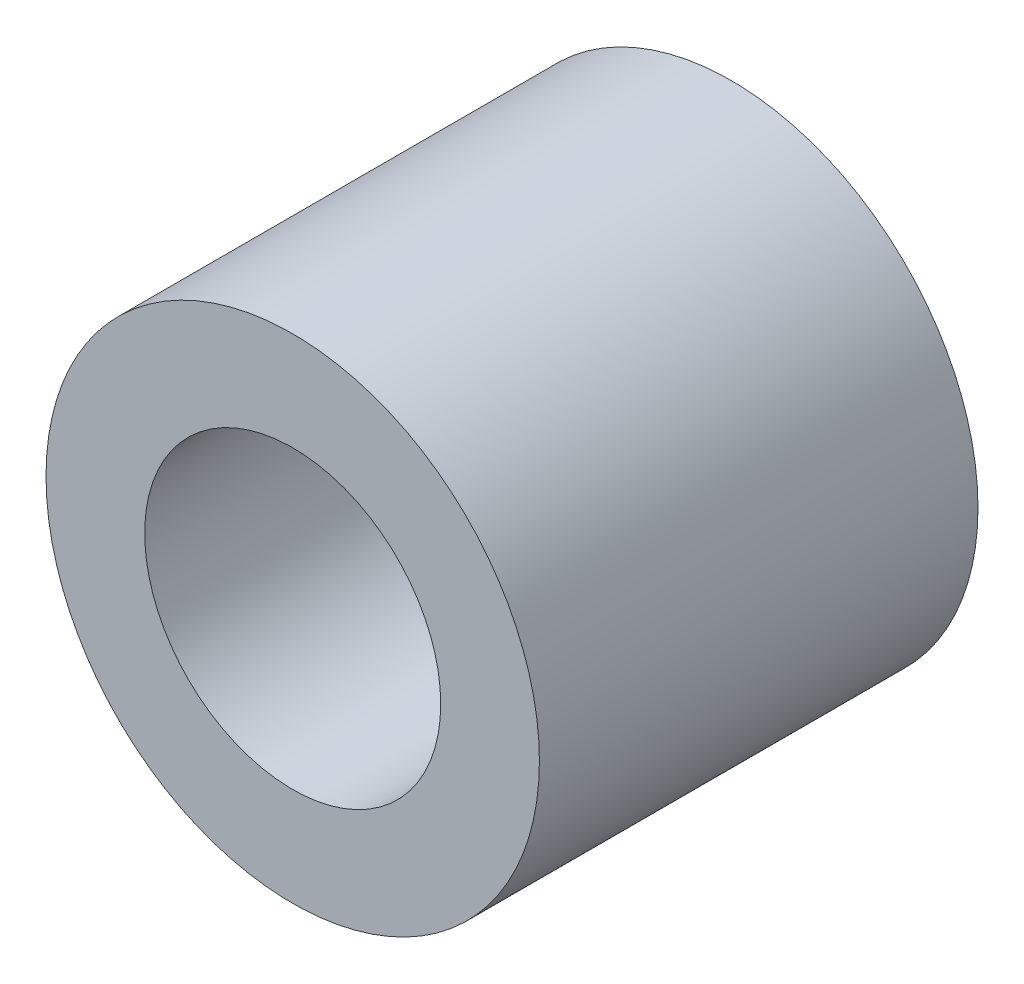
from build123d import *

# Parameters (mm, degrees)
SKETCH1_R      = 2.25
SKETCH1_R_2    = 1.35
EXTRUDE1_DEPTH = 2


with BuildPart() as part:
    # Sketch1 → Extrude1 (new body, symmetric)
    with BuildSketch(Plane.XY):
        Circle(SKETCH1_R)
        Circle(SKETCH1_R_2, mode=Mode.SUBTRACT)
    extrude(amount=EXTRUDE1_DEPTH, both=True)


solid = part.part
